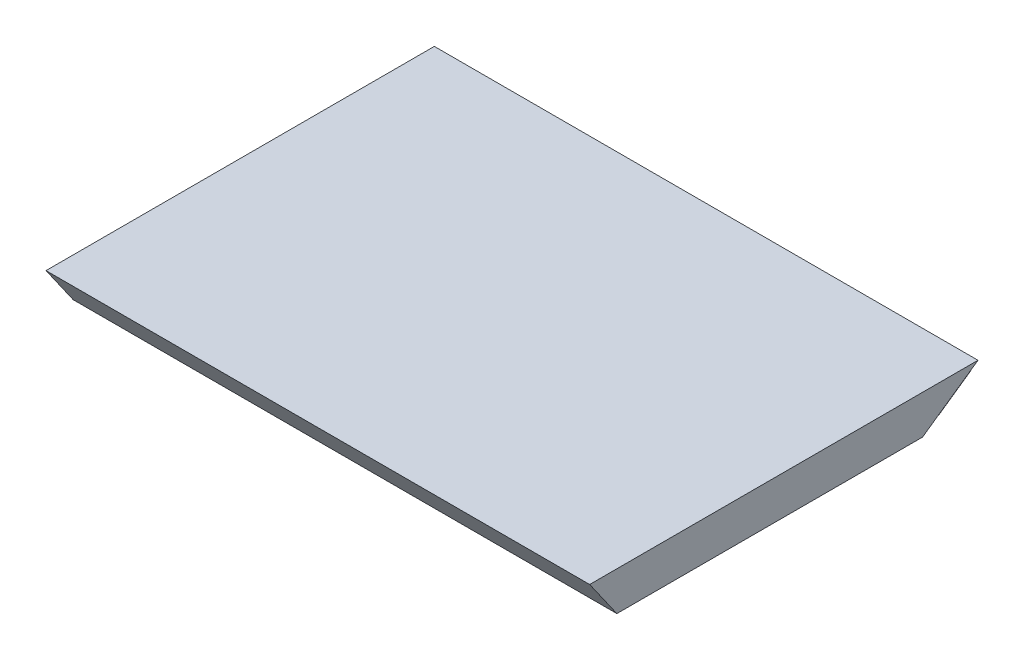
from build123d import *

# Parameters (mm, degrees)
BOSS_EXTRUDE2_DEPTH = 44.45
SKETCH4_W           = 76.2
SKETCH4_H           = 6.35
BOSS_EXTRUDE3_DEPTH = 8.89


with BuildPart() as part:
    # Sketch2 → Boss-Extrude2 (new body, symmetric)
    with BuildSketch(Plane(origin=(0, 0, 0), x_dir=(0, 0, -1), z_dir=(1, 0, 0))):
        Polygon((22.681260157, -3.175), (31.75, 3.175), (-31.75, 3.175), (-27.303682132, -3.175), align=None)
    extrude(amount=BOSS_EXTRUDE2_DEPTH, both=True)

    # Sketch4 → Boss-Extrude3 (add)
    with BuildSketch(Plane(origin=(0, -12.787163377, -8.953668189), x_dir=(1, 0, 0), z_dir=(0, -0.819152044, -0.573576436))):
        with Locations((0, -24.654182592)):
            Rectangle(SKETCH4_W, SKETCH4_H)
    extrude(amount=BOSS_EXTRUDE3_DEPTH)


solid = part.part
